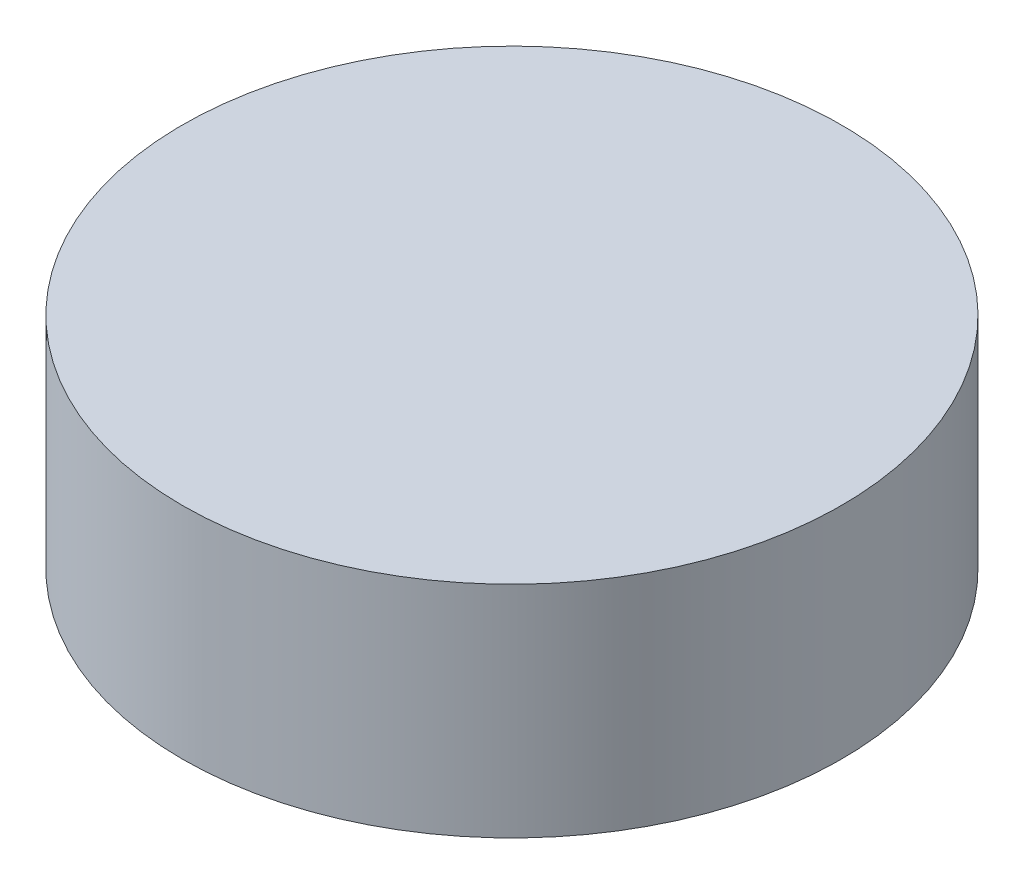
from build123d import *

# Parameters (mm, degrees)
SKETCH1_R           = 38.1
BOSS_EXTRUDE1_DEPTH = 25.4


with BuildPart() as part:
    # Sketch1 → Boss-Extrude1 (new body)
    with BuildSketch(Plane(origin=(0, 0, 0), x_dir=(1, 0, 0), z_dir=(0, 1, 0))):
        Circle(SKETCH1_R)
    extrude(amount=BOSS_EXTRUDE1_DEPTH)


solid = part.part
